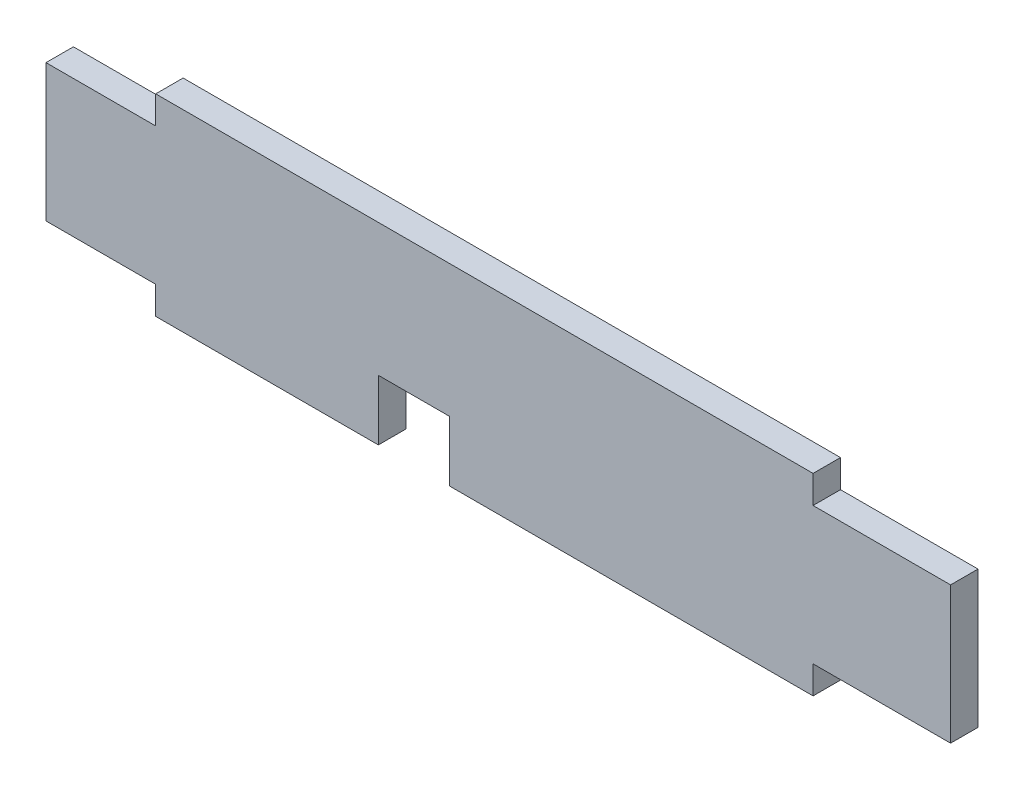
from build123d import *

# Parameters (mm, degrees)
SKETCH_1_W      = 119.86
SKETCH_1_H      = 5.07
SKETCH_1_W_2    = 40.6
SKETCH_1_W_3    = 66.26
EXTRUDE_1_DEPTH = 5


with BuildPart() as part:
    # ｽｹｯﾁ1 → ﾎﾞｽ - 押し出し1 (new body)
    with BuildSketch(Plane.XY):
        Polygon((0, 25), (0, 0), (20, 0), (60.6, 0), (60.6, 5.93), (73.6, 5.93), (73.6, 0), (139.86, 0), (164.93, 0), (164.93, 25), (139.86, 25), (20, 25), align=None)
        with Locations((79.93, 27.535)):
            Rectangle(SKETCH_1_W, SKETCH_1_H)
        with Locations((40.3, -2.535)):
            Rectangle(SKETCH_1_W_2, SKETCH_1_H)
        with Locations((106.73, -2.535)):
            Rectangle(SKETCH_1_W_3, SKETCH_1_H)
    extrude(amount=EXTRUDE_1_DEPTH)


solid = part.part
